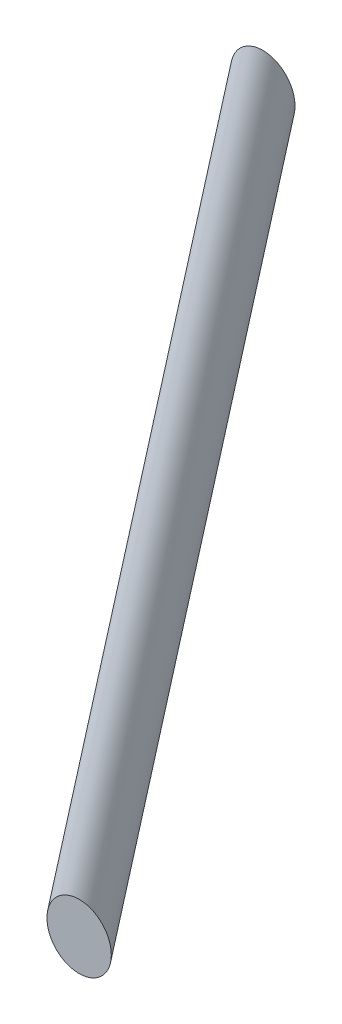
from build123d import *

# Parameters (mm, degrees)
SKETCH3_R = 4.349054689


with BuildPart() as part:
    # Sweep1: sweep along a path in Sketch2
    with BuildLine(Plane(origin=(110.418238983, -191.25, 0), x_dir=(0.866025404, 0.5, 0), z_dir=(-0.5, 0.866025404, 0))) as sweep1_path:
        Line((-127.5, -230.502374751), (-365, 0))
    # Sketch3 → Sweep1 (sweep)
    with BuildSketch(Plane.XY):
        with Locations((-205.681033399, -373.75)):
            Circle(SKETCH3_R)
    sweep(path=sweep1_path.line)


solid = part.part
